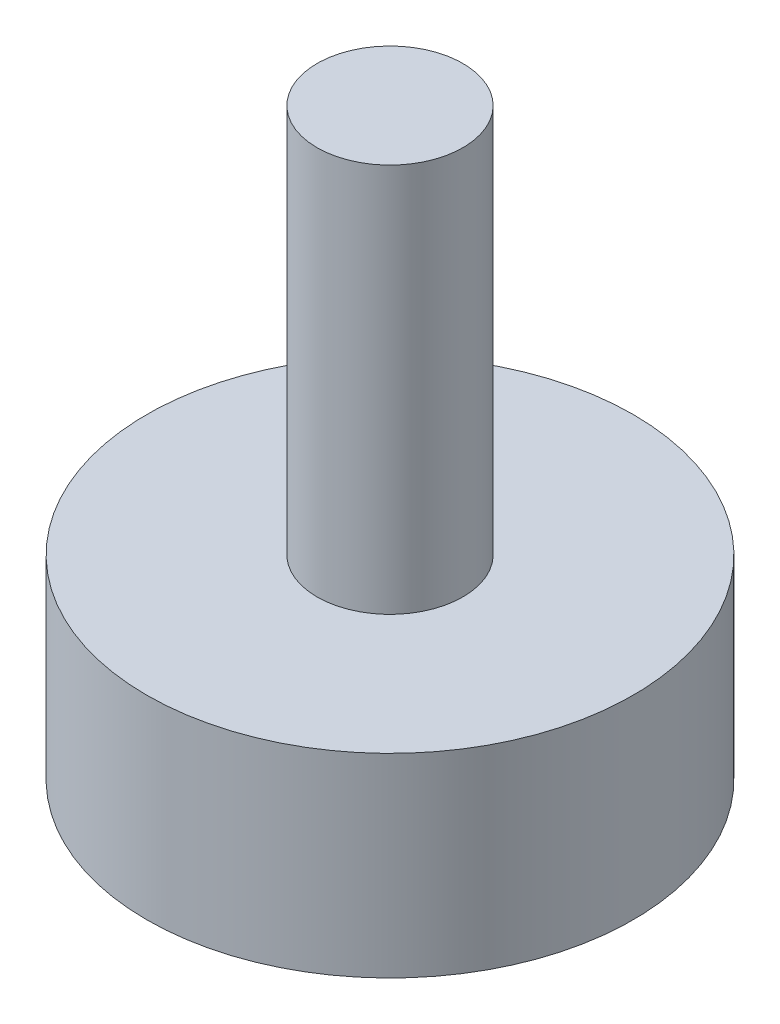
from build123d import *

# Parameters (mm, degrees)
SKETCH_1_R      = 1.5
EXTRUDE_1_DEPTH = 8
SKETCH_2_R      = 5
EXTRUDE_2_DEPTH = 4


with BuildPart() as part:
    # 草图1 → 凸台-拉伸1 (new body)
    with BuildSketch(Plane(origin=(0, 0, 0), x_dir=(1, 0, 0), z_dir=(0, 1, 0))):
        Circle(SKETCH_1_R)
    extrude(amount=EXTRUDE_1_DEPTH)

    # 草图2 → 凸台-拉伸2 (add)
    with BuildSketch(Plane.XZ):
        Circle(SKETCH_2_R)
    extrude(amount=EXTRUDE_2_DEPTH)


solid = part.part
